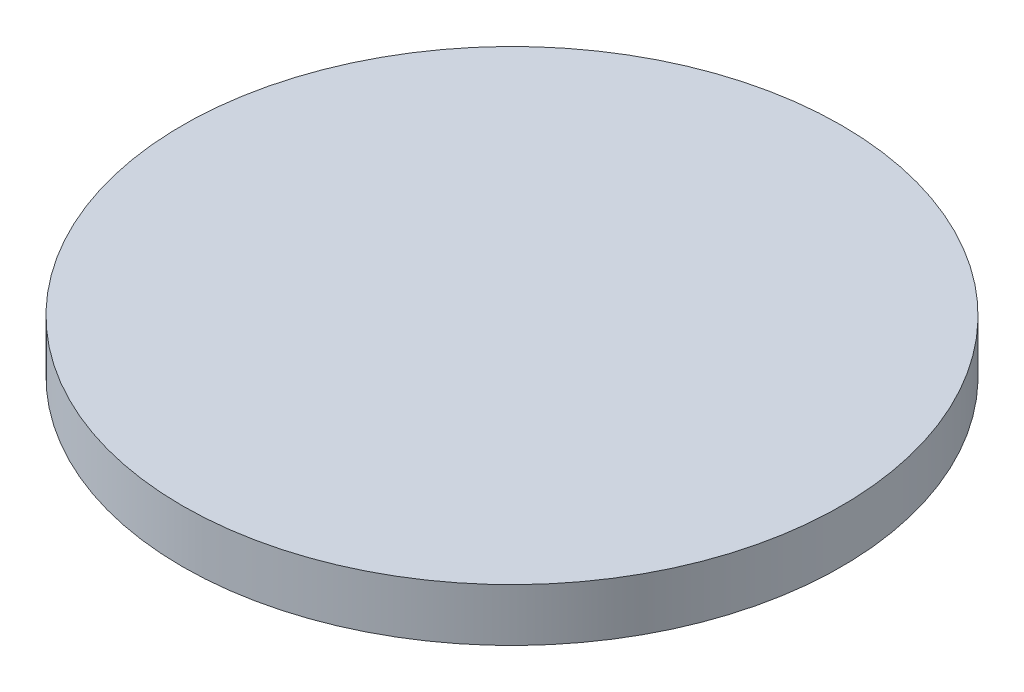
from build123d import *

# Parameters (mm, degrees)
SKETCH1_R           = 19.84375
BOSS_EXTRUDE1_DEPTH = 3.175


with BuildPart() as part:
    # Sketch1 → Boss-Extrude1 (new body)
    with BuildSketch(Plane(origin=(0, 0, 0), x_dir=(1, 0, 0), z_dir=(0, 1, 0))):
        Circle(SKETCH1_R)
    extrude(amount=BOSS_EXTRUDE1_DEPTH)


solid = part.part
